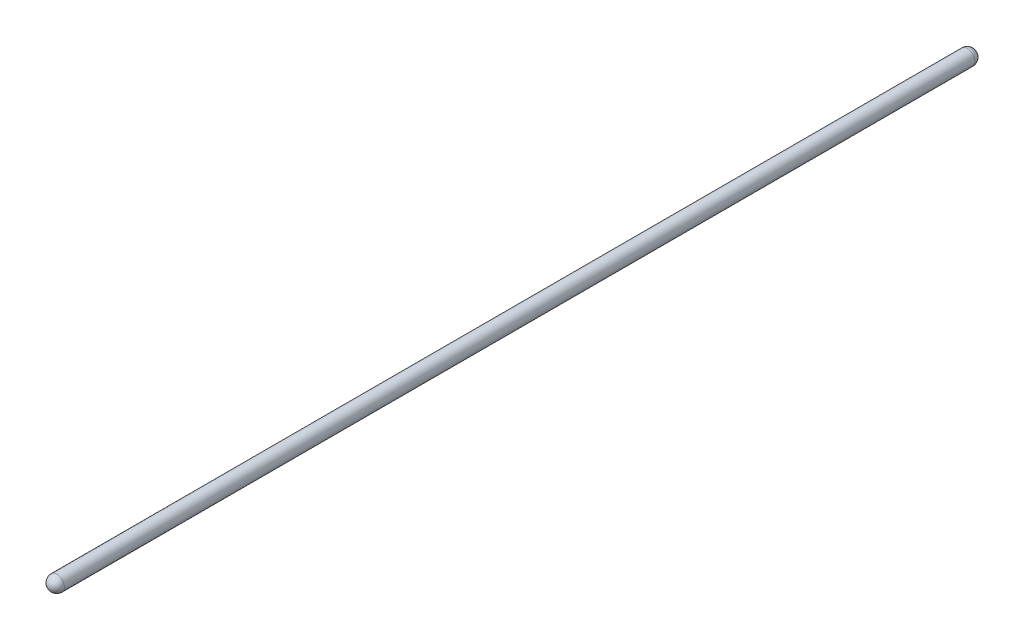
from build123d import *


with BuildPart() as part:
    # Sketch1 → Revolve1 (revolve)
    with BuildSketch(Plane(origin=(0, 0, 0), x_dir=(1, 0, 0), z_dir=(0, 1, 0))):
        with BuildLine():
            Line((9.525, 0), (9.525, -1138.76328))
            ThreePointArc((9.525, -1138.76328), (6.735192091, -1145.498472091), (0, -1148.28828))
            Line((0, -1148.28828), (0, 9.525))
            ThreePointArc((0, 9.525), (6.735192091, 6.735192091), (9.525, 0))
        make_face()
    revolve(axis=Axis((0, 0, -9.525), (0, 0, 1)))


solid = part.part
